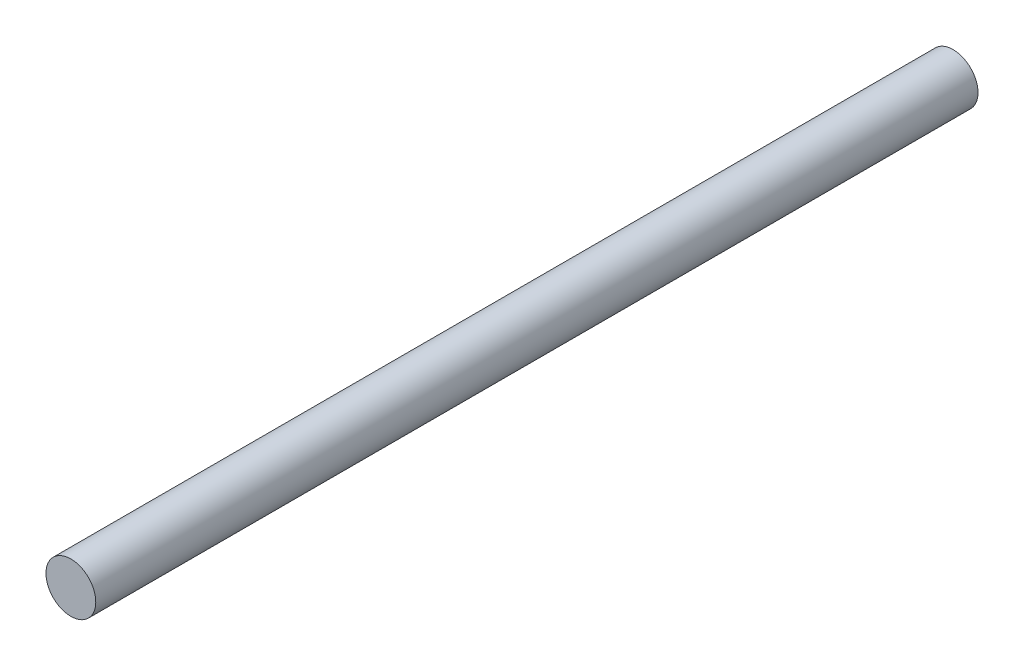
from build123d import *

# Parameters (mm, degrees)
CROQUIS1_R              = 1.85
SALIENTE_EXTRUIR1_DEPTH = 65.535


with BuildPart() as part:
    # Croquis1 → Saliente-Extruir1 (new body)
    with BuildSketch(Plane.XY):
        Circle(CROQUIS1_R)
    extrude(amount=SALIENTE_EXTRUIR1_DEPTH)


solid = part.part
